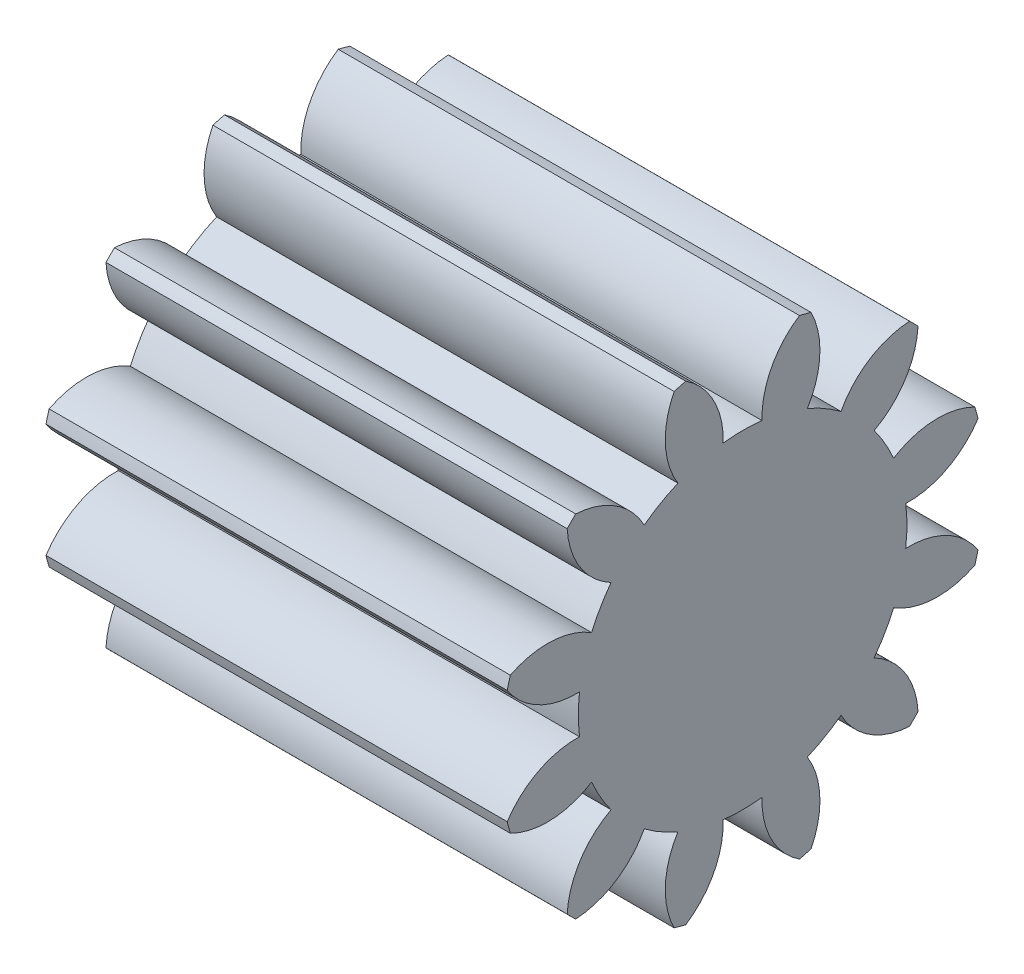
from build123d import *

# Parameters (mm, degrees)
BASPROSKE_W         = 12
BASPROSKE_H         = 6.3
TOOTHCUT_DEPTH      = 15.945902448
TEETHCUTS_COUNT     = 12
TEETHCUTS_ANGLE     = 330
BORE_DEPTH          = 50.0000508
BOSS_EXTRUDE1_DEPTH = 12


with BuildPart() as part:
    # BasProSke → Base-Revolve (revolve)
    with BuildSketch(Plane(origin=(0, 0, 0), x_dir=(1, 0, 0), z_dir=(0, 1, 0)), mode=Mode.PRIVATE) as base_revolve_sk:
        with Locations((6, 3.15)):
            Rectangle(BASPROSKE_W, BASPROSKE_H)
    revolve(base_revolve_sk.sketch.rotate(Axis((-10, 0, 0), (1, 0, 0)), 180), axis=Axis((-10, 0, 0), (1, 0, 0)))

    # TooCutSke → ToothCut (cut, through all)
    with BuildSketch(Plane(origin=(0, 0, 0), x_dir=(0, 0, -1), z_dir=(1, 0, 0))):
        with BuildLine():
            ThreePointArc((0.505712998, 4.243975773), (0, 4.274), (-0.505712998, 4.243975773))
            ThreePointArc((-0.505712998, 4.243975773), (-0.754225381, 5.326869831), (-1.508135905, 6.142980649))
            ThreePointArc((-1.508135905, 6.142980649), (0, 6.3254), (1.508135905, 6.142980649))
            ThreePointArc((1.508135905, 6.142980649), (0.754225381, 5.326869831), (0.505712998, 4.243975773))
        make_face()
    toothcut = extrude(amount=TOOTHCUT_DEPTH, mode=Mode.SUBTRACT)

    # TeethCuts: ToothCut ×12 about axis
    teethcuts_axis = Axis((-10, 0, 0), (1, 0, 0))
    for i in range(1, TEETHCUTS_COUNT):
        add(toothcut.rotate(teethcuts_axis, i * TEETHCUTS_ANGLE / (TEETHCUTS_COUNT - 1)), mode=Mode.SUBTRACT)

    # BorSke → Bore (cut, symmetric)
    with BuildSketch(Plane(origin=(0, 0, 0), x_dir=(0, 0, -1), z_dir=(1, 0, 0))):
        with BuildLine():
            Line((-1.5, 2), (1.5, 2))
            ThreePointArc((1.5, 2), (0, -2.5), (-1.5, 2))
        make_face()
    extrude(amount=BORE_DEPTH, both=True, mode=Mode.SUBTRACT)

    # Sketch1 → Boss-Extrude1 (add)
    with BuildSketch(Plane(origin=(12, 0, 0), x_dir=(0, 0, -1), z_dir=(1, 0, 0))):
        with BuildLine():
            Line((1.5, 2), (-1.5, 2))
            ThreePointArc((-1.5, 2), (0, -2.5), (1.5, 2))
        make_face()
    extrude(amount=-BOSS_EXTRUDE1_DEPTH)


solid = part.part
